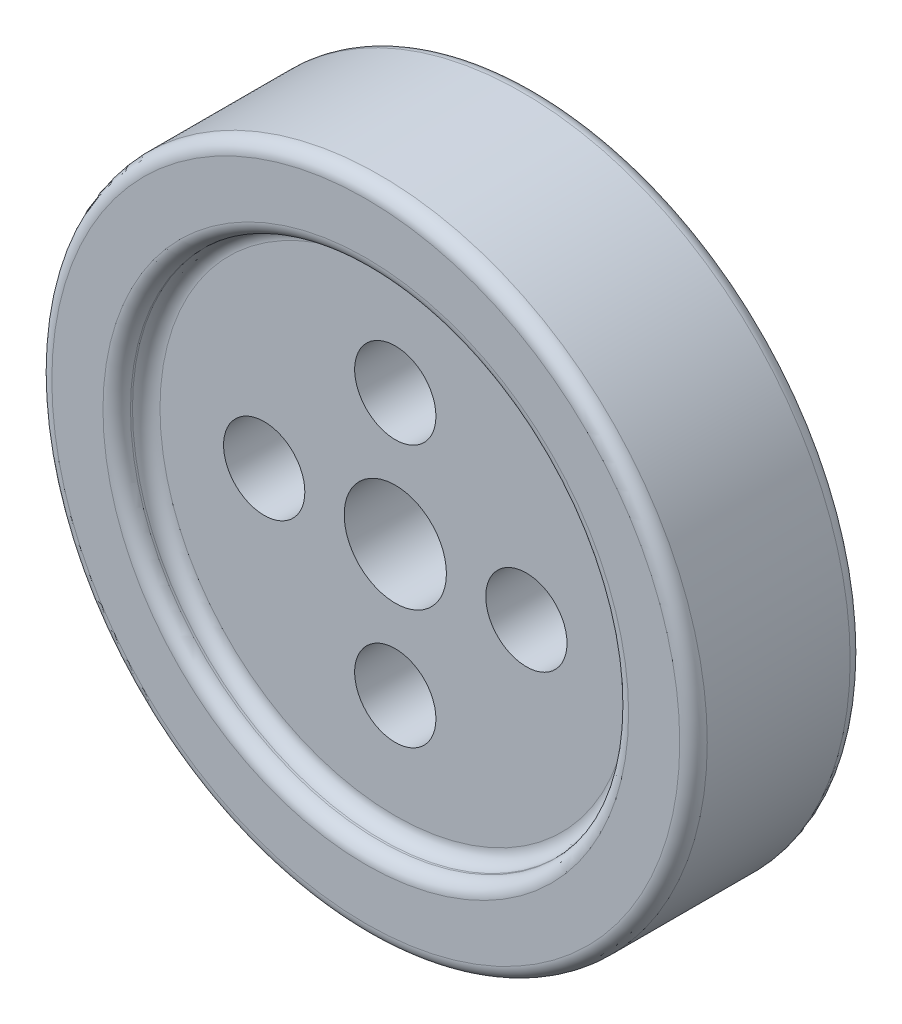
from build123d import *

# Parameters (mm, degrees)
SKETCH2_R           = 250
BOSS_EXTRUDE1_DEPTH = 130
SKETCH3_R           = 190
CUT_EXTRUDE1_DEPTH  = 22.5
FILLET5_R           = 10.5
FILLET6_R           = 10.5
SKETCH4_R           = 190
CUT_EXTRUDE2_DEPTH  = 22.5
FILLET7_R           = 10.5
SKETCH5_R           = 31
CUT_EXTRUDE3_DEPTH  = 108.5
SKETCH6_R           = 39
CUT_EXTRUDE4_DEPTH  = 108.5


with BuildPart() as part:
    # Sketch2 → Boss-Extrude1 (new body)
    with BuildSketch(Plane.XY):
        Circle(SKETCH2_R)
    extrude(amount=BOSS_EXTRUDE1_DEPTH)

    # Sketch3 → Cut-Extrude1 (cut, symmetric)
    with BuildSketch(Plane.XY.offset(130)):
        Circle(SKETCH3_R)
    extrude(amount=CUT_EXTRUDE1_DEPTH, both=True, mode=Mode.SUBTRACT)

    # Fillet5
    fillet5_edges = [part.edges().sort_by_distance(p)[0] for p in [
        (-190, 0, 130),
        (-190, 0, 107.5),
    ]]
    fillet(fillet5_edges, radius=FILLET5_R)

    # Fillet6
    fillet6_edges = [part.edges().sort_by_distance(p)[0] for p in [
        (-250, 0, 130),
    ]]
    fillet(fillet6_edges, radius=FILLET6_R)

    # Sketch4 → Cut-Extrude2 (cut, symmetric)
    with BuildSketch(Plane(origin=(0, 0, 0), x_dir=(-1, 0, 0), z_dir=(0, 0, -1))):
        Circle(SKETCH4_R)
    extrude(amount=CUT_EXTRUDE2_DEPTH, both=True, mode=Mode.SUBTRACT)

    # Fillet7
    fillet7_edges = [part.edges().sort_by_distance(p)[0] for p in [
        (-250, 0, 0),
        (190, 0, 22.5),
        (190, 0, 0),
    ]]
    fillet(fillet7_edges, radius=FILLET7_R)

    # Sketch5 → Cut-Extrude3 (cut, through all)
    with BuildSketch(Plane.XY.offset(107.5)):
        with Locations((0, 100)):
            Circle(SKETCH5_R)
        with Locations((100, 0)):
            Circle(SKETCH5_R)
        with Locations((0, -100)):
            Circle(SKETCH5_R)
        with Locations((-100, 0)):
            Circle(SKETCH5_R)
    extrude(amount=-CUT_EXTRUDE3_DEPTH, mode=Mode.SUBTRACT)

    # Sketch6 → Cut-Extrude4 (cut, through all)
    with BuildSketch(Plane.XY.offset(107.5)):
        Circle(SKETCH6_R)
    extrude(amount=-CUT_EXTRUDE4_DEPTH, mode=Mode.SUBTRACT)


solid = part.part
